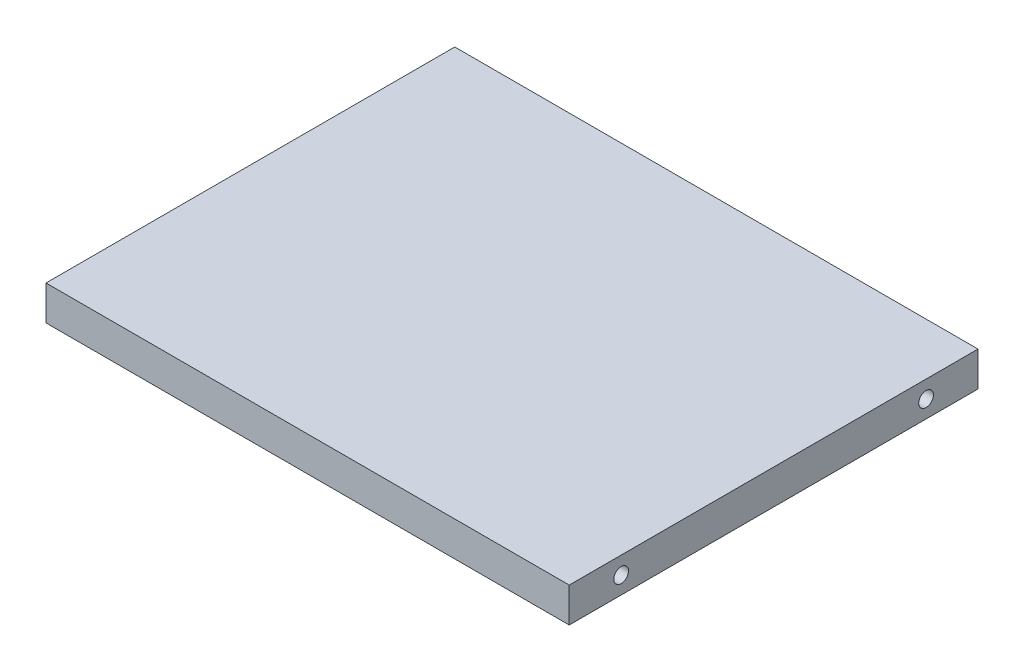
from build123d import *

# Parameters (mm, degrees)
SKETCH1_W           = 96
SKETCH1_H           = 75
BOSS_EXTRUDE1_DEPTH = 6.35
SKETCH2_R           = 1.35255
CUT_EXTRUDE1_DEPTH  = 9.525
SKETCH3_R           = 1.35255
CUT_EXTRUDE2_DEPTH  = 9.525


with BuildPart() as part:
    # Sketch1 → Boss-Extrude1 (new body)
    with BuildSketch(Plane(origin=(0, 80, 0), x_dir=(1, 0, 0), z_dir=(0, 1, 0))):
        with Locations((48, 37.5)):
            Rectangle(SKETCH1_W, SKETCH1_H)
    extrude(amount=-BOSS_EXTRUDE1_DEPTH)

    # Sketch2 → Cut-Extrude1 (cut)
    with BuildSketch(Plane(origin=(96, 0, 0), x_dir=(0, 0, -1), z_dir=(1, 0, 0))):
        with Locations((65.475, 76.825)):
            Circle(SKETCH2_R)
        with Locations((9.525, 76.825)):
            Circle(SKETCH2_R)
    extrude(amount=-CUT_EXTRUDE1_DEPTH, mode=Mode.SUBTRACT)

    # Sketch3 → Cut-Extrude2 (cut)
    with BuildSketch(Plane.ZY):
        with Locations((-65.475, 76.825)):
            Circle(SKETCH3_R)
        with Locations((-9.525, 76.825)):
            Circle(SKETCH3_R)
    extrude(amount=-CUT_EXTRUDE2_DEPTH, mode=Mode.SUBTRACT)


solid = part.part
